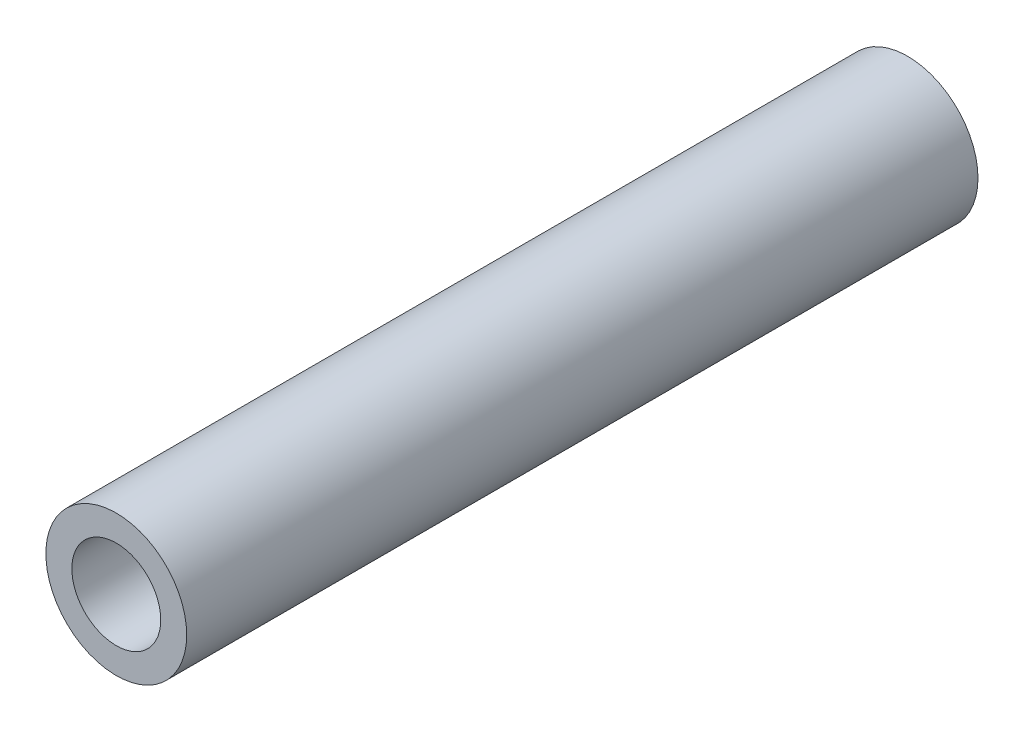
from build123d import *

# Parameters (mm, degrees)
SKETCH1_R           = 5.425
SKETCH1_R_2         = 3.425
BOSS_EXTRUDE1_DEPTH = 60.96


with BuildPart() as part:
    # Sketch1 → Boss-Extrude1 (new body)
    with BuildSketch(Plane.XY):
        Circle(SKETCH1_R)
        Circle(SKETCH1_R_2, mode=Mode.SUBTRACT)
    extrude(amount=BOSS_EXTRUDE1_DEPTH)


solid = part.part
